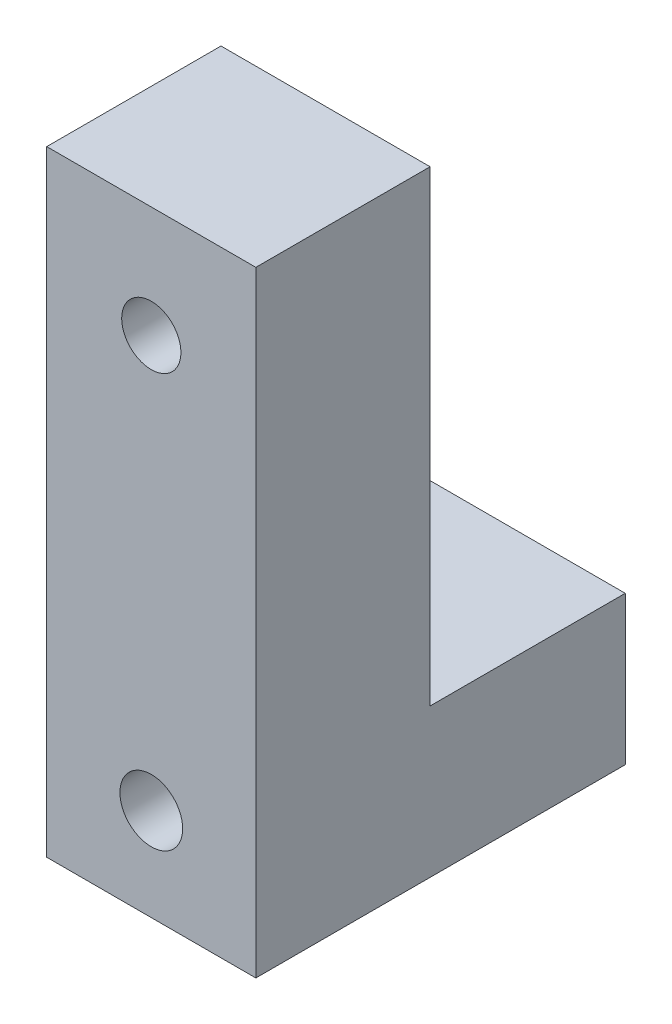
from build123d import *

# Parameters (mm, degrees)
EXTRUDE_1_DEPTH     = 30
SKETCH_2_R          = 2.65
CUT_EXTRUDE_1_DEPTH = 54
SKETCH_4_R          = 4.5
CUT_EXTRUDE_3_DEPTH = 40
SKETCH_5_R          = 4.25
CUT_EXTRUDE_4_DEPTH = 26
SKETCH_6_R          = 7
CUT_EXTRUDE_5_DEPTH = 8


with BuildPart() as part:
    # 草图1 → 凸台-拉伸1 (new body)
    with BuildSketch(Plane(origin=(0, 0, 0), x_dir=(0, 0, -1), z_dir=(1, 0, 0))):
        Polygon((-18.5, 8), (-18.5, -13.3), (-71.5, -13.3), (-71.5, 75), (-46.5, 75), (-46.5, 8), align=None)
    extrude(amount=EXTRUDE_1_DEPTH)

    # 草图2 → 切除-拉伸1 (cut, through all)
    with BuildSketch(Plane(origin=(0, 0, 18.5), x_dir=(-1, 0, 0), z_dir=(0, 0, -1))):
        with Locations((-15, 0)):
            Circle(SKETCH_2_R)
    extrude(amount=-CUT_EXTRUDE_1_DEPTH, mode=Mode.SUBTRACT)

    # 草图4 → 切除-拉伸3 (cut, through all)
    with BuildSketch(Plane(origin=(0, 0, 32.5), x_dir=(-1, 0, 0), z_dir=(0, 0, -1))):
        with Locations((-15, 0)):
            Circle(SKETCH_4_R)
    extrude(amount=-CUT_EXTRUDE_3_DEPTH, mode=Mode.SUBTRACT)

    # 草图5 → 切除-拉伸4 (cut, through all)
    with BuildSketch(Plane(origin=(0, 0, 46.5), x_dir=(-1, 0, 0), z_dir=(0, 0, -1))):
        with Locations((-15, 59.038200963)):
            Circle(SKETCH_5_R)
    extrude(amount=-CUT_EXTRUDE_4_DEPTH, mode=Mode.SUBTRACT)

    # 草图6 → 切除-拉伸5 (cut)
    with BuildSketch(Plane(origin=(0, 0, 46.5), x_dir=(-1, 0, 0), z_dir=(0, 0, -1))):
        with Locations((-15, 59.038200963)):
            Circle(SKETCH_6_R)
    extrude(amount=-CUT_EXTRUDE_5_DEPTH, mode=Mode.SUBTRACT)


solid = part.part
